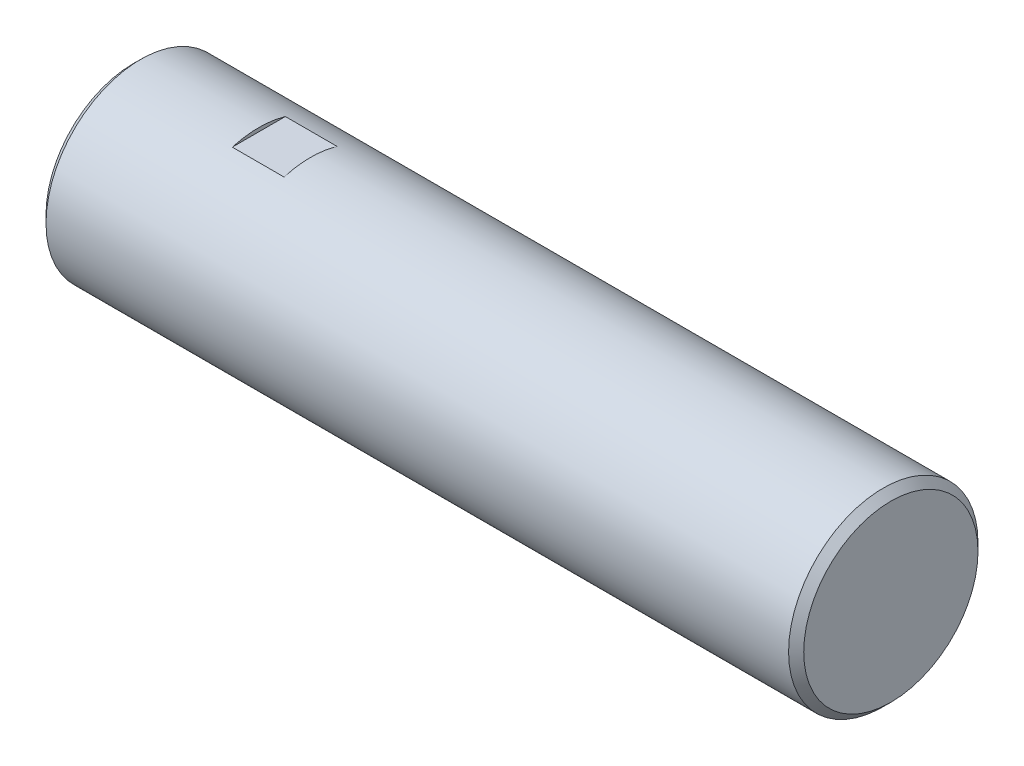
from build123d import *

# Parameters (mm, degrees)
SKETCH2_R               = 3.175
BOSS_EXTRUDE1_DEPTH     = 25.4
CHAMFER1_SIZE           = 0.254
SKETCH3_W               = 1.733713748
SKETCH3_H               = 3.25599899
CUT_EXTRUDE1_DEPTH      = 4.175
CUT_EXTRUDE1_DEPTH_BACK = 4.175


with BuildPart() as part:
    # Sketch2 → Boss-Extrude1 (new body)
    with BuildSketch(Plane(origin=(0, 0, 0), x_dir=(0, 0, -1), z_dir=(1, 0, 0))):
        Circle(SKETCH2_R)
    extrude(amount=BOSS_EXTRUDE1_DEPTH)

    # Chamfer1
    chamfer1_edges = [part.edges().sort_by_distance(p)[0] for p in [
        (0, 0, 3.175),
        (25.4, 0, 3.175),
    ]]
    chamfer(chamfer1_edges, length=CHAMFER1_SIZE)

    # Sketch3 → Cut-Extrude1 (cut, two sides)
    with BuildSketch(Plane.XY) as cut_extrude1_sk:
        with Locations((5.08, 4.675999495)):
            Rectangle(SKETCH3_W, SKETCH3_H)
    extrude(amount=CUT_EXTRUDE1_DEPTH, mode=Mode.SUBTRACT)
    extrude(cut_extrude1_sk.sketch, amount=-CUT_EXTRUDE1_DEPTH_BACK, mode=Mode.SUBTRACT)


solid = part.part
